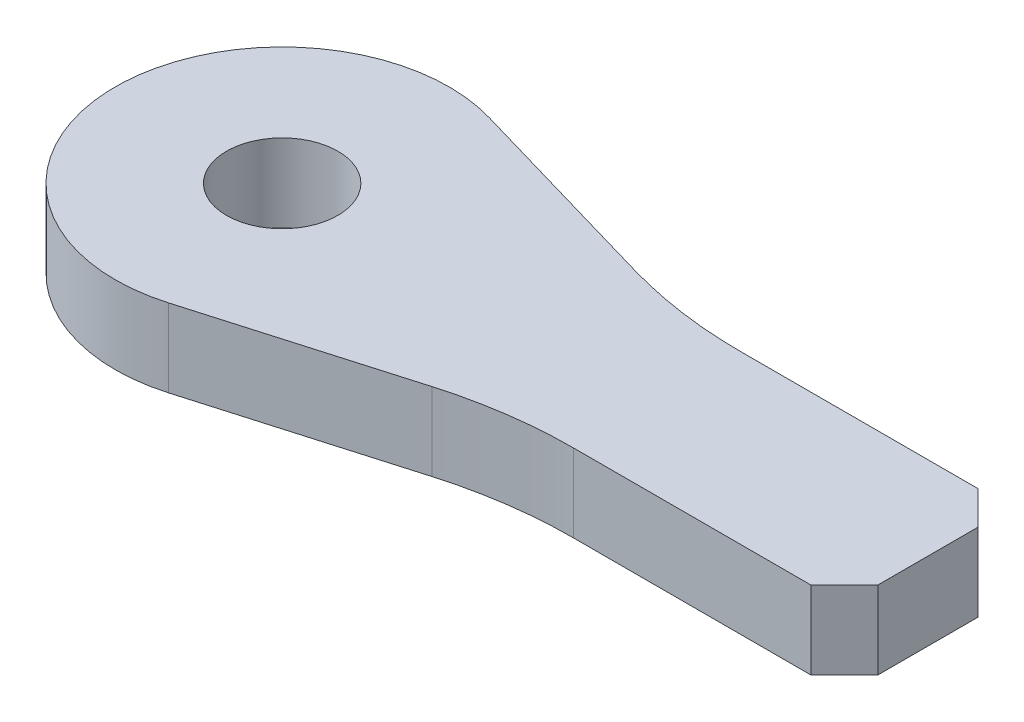
from build123d import *

# Parameters (mm, degrees)
SKETCH1_R           = 5
BOSS_EXTRUDE1_DEPTH = 7


with BuildPart() as part:
    # Sketch1 → Boss-Extrude1 (new body)
    with BuildSketch(Plane(origin=(0, 0, 0), x_dir=(1, 0, 0), z_dir=(0, 1, 0))):
        with BuildLine():
            Line((37.5, -4.5), (37.5, 4.5))
            Line((37.5, 4.5), (34.5, 7.5))
            Line((34.5, 7.5), (13.183654114, 7.5))
            ThreePointArc((13.183654114, 7.5), (7.556521898, 7.89778563), (2.041309299, 9.083230849))
            Line((2.041309299, 9.083230849), (-16.311620694, 14.406288432))
            ThreePointArc((-16.311620694, 14.406288432), (-35.49, 0), (-16.311620694, -14.406288432))
            Line((-16.311620694, -14.406288432), (2.041309299, -9.083230849))
            ThreePointArc((2.041309299, -9.083230849), (7.556521898, -7.89778563), (13.183654114, -7.5))
            Line((13.183654114, -7.5), (34.5, -7.5))
            Line((34.5, -7.5), (37.5, -4.5))
        make_face()
        with Locations((-20.49, 0)):
            Circle(SKETCH1_R, mode=Mode.SUBTRACT)
    extrude(amount=BOSS_EXTRUDE1_DEPTH)


solid = part.part
